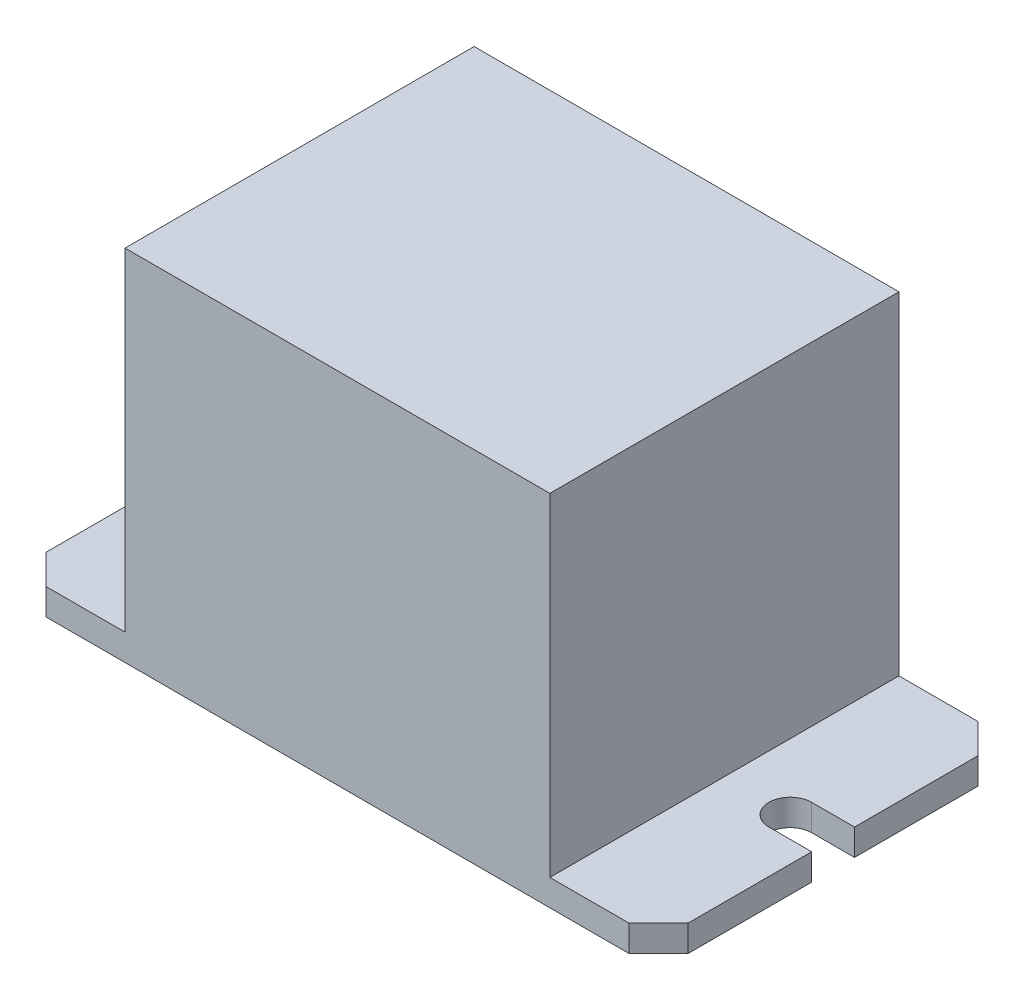
from build123d import *

# Parameters (mm, degrees)
SKETCH1_W           = 32.766
SKETCH1_H           = 26.924
BOSS_EXTRUDE1_DEPTH = 27.686
BOSS_EXTRUDE2_DEPTH = 2.032
BOSS_EXTRUDE3_DEPTH = 2.032


with BuildPart() as part:
    # Sketch1 → Boss-Extrude1 (new body)
    with BuildSketch(Plane(origin=(0, 0, 0), x_dir=(1, 0, 0), z_dir=(0, 1, 0))):
        with Locations((-1.646230698, -0.06385993)):
            Rectangle(SKETCH1_W, SKETCH1_H)
    extrude(amount=BOSS_EXTRUDE1_DEPTH)

    # Sketch1_12 → Boss-Extrude2 (add)
    with BuildSketch(Plane(origin=(0, 0, 0), x_dir=(1, 0, 0), z_dir=(0, 1, 0))):
        with BuildLine():
            Line((-18.029230698, 13.39814007), (-18.029230698, -13.52585993))
            Line((-18.029230698, -13.52585993), (-24.125230698, -13.52585993))
            Line((-24.125230698, -13.52585993), (-26.411230698, -11.23985993))
            Line((-26.411230698, -11.23985993), (-26.411230698, -1.71485993))
            Line((-26.411230698, -1.71485993), (-23.109230698, -1.71485993))
            ThreePointArc((-23.109230698, -1.71485993), (-21.458230698, -0.06385993), (-23.109230698, 1.58714007))
            Line((-23.109230698, 1.58714007), (-26.411230698, 1.58714007))
            Line((-26.411230698, 1.58714007), (-26.411230698, 11.11214007))
            Line((-26.411230698, 11.11214007), (-24.125230698, 13.39814007))
            Line((-24.125230698, 13.39814007), (-18.029230698, 13.39814007))
        make_face()
    extrude(amount=BOSS_EXTRUDE2_DEPTH)

    # Sketch1_13 → Boss-Extrude3 (add)
    with BuildSketch(Plane(origin=(0, 0, 0), x_dir=(1, 0, 0), z_dir=(0, 1, 0))):
        with BuildLine():
            Line((20.832769302, -13.52585993), (14.736769302, -13.52585993))
            Line((14.736769302, -13.52585993), (14.736769302, 13.39814007))
            Line((14.736769302, 13.39814007), (20.832769302, 13.39814007))
            Line((20.832769302, 13.39814007), (23.118769302, 11.11214007))
            Line((23.118769302, 11.11214007), (23.118769302, 1.58714007))
            Line((23.118769302, 1.58714007), (19.816769302, 1.58714007))
            ThreePointArc((19.816769302, 1.58714007), (18.165769302, -0.06385993), (19.816769302, -1.71485993))
            Line((19.816769302, -1.71485993), (23.118769302, -1.71485993))
            Line((23.118769302, -1.71485993), (23.118769302, -11.23985993))
            Line((23.118769302, -11.23985993), (20.832769302, -13.52585993))
        make_face()
    extrude(amount=BOSS_EXTRUDE3_DEPTH)


solid = part.part
